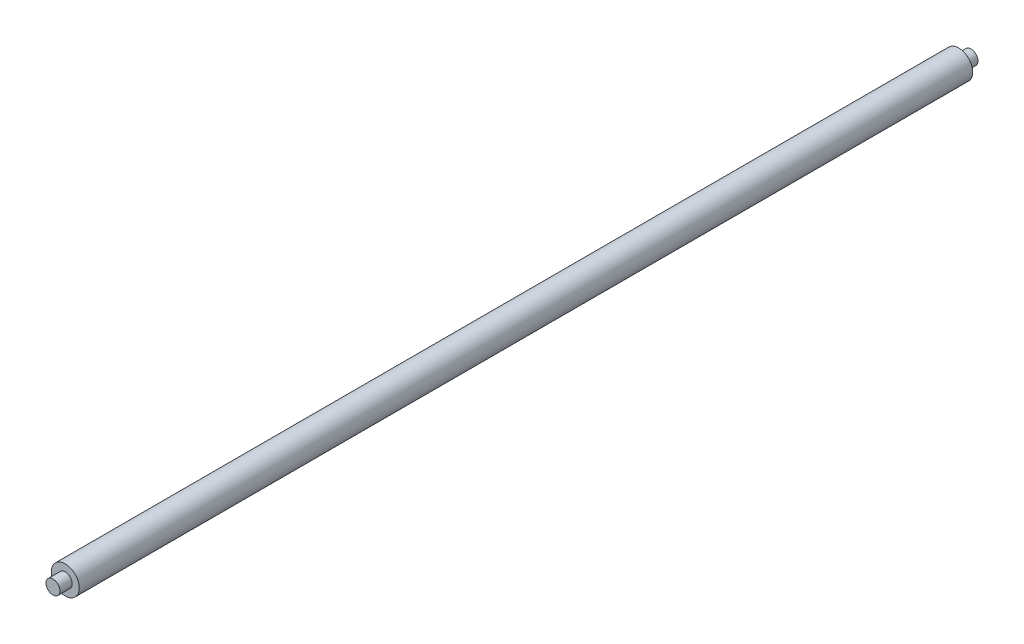
from build123d import *

# Parameters (mm, degrees)
SKETCH1_R           = 6.25
BOSS_EXTRUDE1_DEPTH = 11
SKETCH2_R           = 12.5
BOSS_EXTRUDE2_DEPTH = 800
SKETCH3_R           = 6.25
BOSS_EXTRUDE3_DEPTH = 11


with BuildPart() as part:
    # Sketch1 → Boss-Extrude1 (new body)
    with BuildSketch(Plane.XY):
        Circle(SKETCH1_R)
    extrude(amount=BOSS_EXTRUDE1_DEPTH)

    # Sketch2 → Boss-Extrude2 (add)
    with BuildSketch(Plane.XY.offset(11)):
        Circle(SKETCH2_R)
    extrude(amount=BOSS_EXTRUDE2_DEPTH)

    # Sketch3 → Boss-Extrude3 (add)
    with BuildSketch(Plane.XY.offset(811)):
        Circle(SKETCH3_R)
    extrude(amount=BOSS_EXTRUDE3_DEPTH)


solid = part.part
